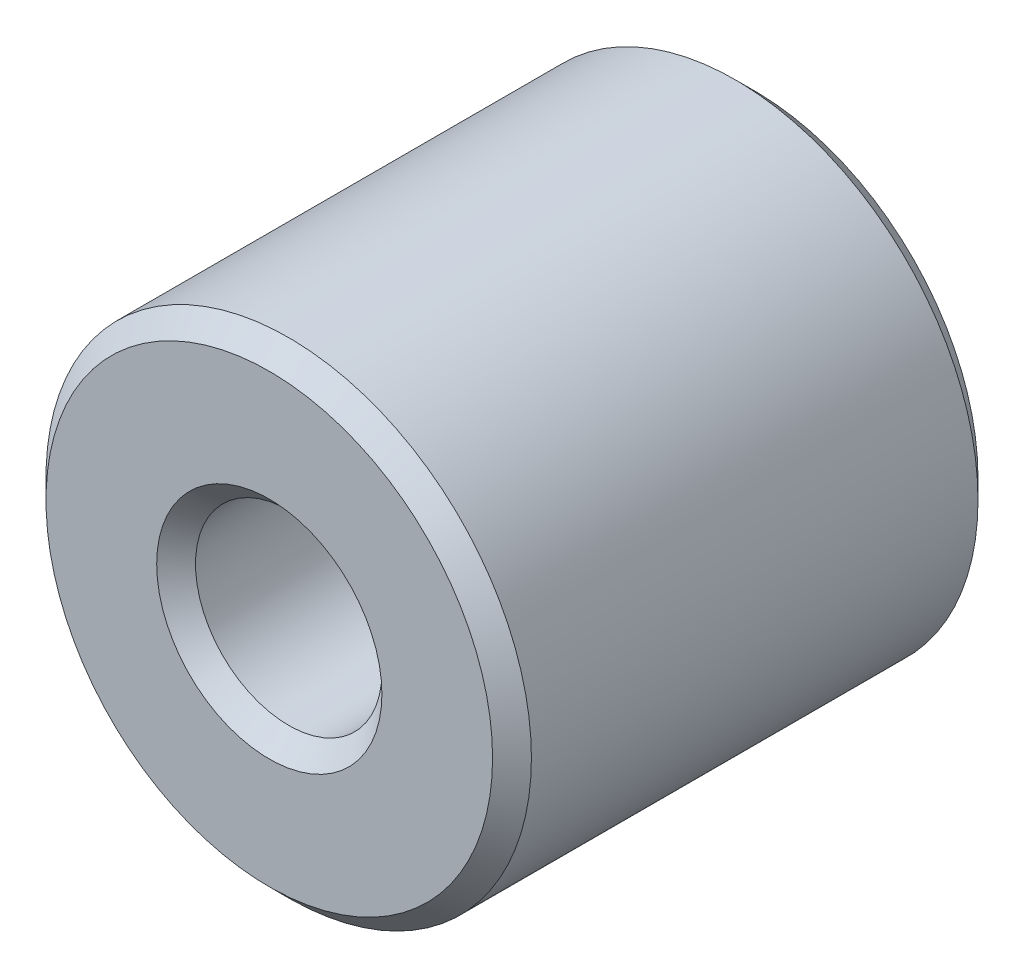
from build123d import *

# Parameters (mm, degrees)
SKETCH3_R                = 6.35
SKETCH3_R_2              = 2.4384
BOSS_EXTRUDE1_DEPTH      = 6.35
BOSS_EXTRUDE1_DEPTH_BACK = 6.35
CHAMFER1_SIZE            = 0.508


with BuildPart() as part:
    # Sketch3 → Boss-Extrude1 (new body, two sides)
    with BuildSketch(Plane.XY) as boss_extrude1_sk:
        Circle(SKETCH3_R)
        Circle(SKETCH3_R_2, mode=Mode.SUBTRACT)
    extrude(amount=BOSS_EXTRUDE1_DEPTH)
    extrude(boss_extrude1_sk.sketch, amount=-BOSS_EXTRUDE1_DEPTH_BACK)

    # Chamfer1
    chamfer1_edges = [part.edges().sort_by_distance(p)[0] for p in [
        (-6.35, 0, -6.35),
        (-2.4384, 0, -6.35),
        (-6.35, 0, 6.35),
        (-2.4384, 0, 6.35),
    ]]
    chamfer(chamfer1_edges, length=CHAMFER1_SIZE)


solid = part.part
